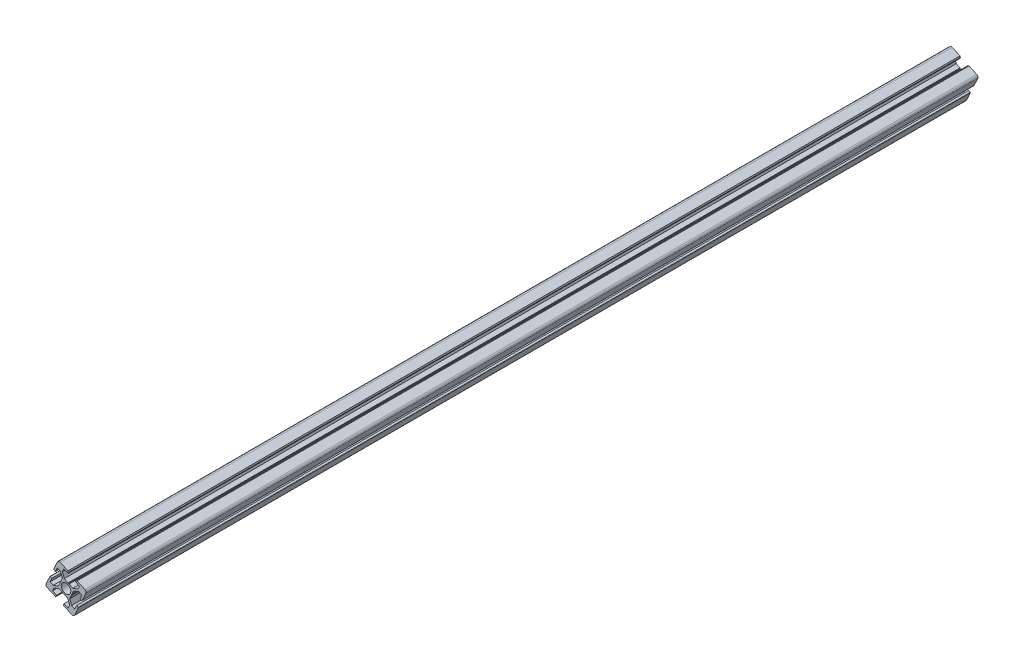
from build123d import *

# Parameters (mm, degrees)
BOSS_EXTRUDE1_DEPTH = 2000
SCALE1_SCALE        = 3
SKETCH2_R           = 115.047789556
CUT_EXTRUDE1_DEPTH  = 1600
SKETCH3_R           = 13.75
CUT_EXTRUDE2_DEPTH  = 4401
SCALE2_SCALE        = 0.466666667
CUT_EXTRUDE3_DEPTH  = 53.3
CUT_EXTRUDE4_DEPTH  = 800


with BuildPart() as part:
    # Sketch1 → Boss-Extrude1 (new body)
    with BuildSketch(Plane.XY):
        with BuildLine():
            Line((-8.216270499, 18.069114507), (-11.842563011, 10.160890774))
            ThreePointArc((-11.842563011, 10.160890774), (-11.851111664, 9.931439908), (-11.694910211, 9.763148835))
            Line((-11.694910211, 9.763148835), (-10.149625113, 9.054562941))
            Line((-10.149625113, 9.054562941), (-8.37816038, 12.917775685))
            Line((-8.37816038, 12.917775685), (-5.345959751, 11.527369089))
            Line((-5.345959751, 11.527369089), (-3.542521768, 6.669331059))
            Line((-3.542521768, 6.669331059), (-5.237363855, 2.973217088))
            Line((-5.237363855, 2.973217088), (-5.181250032, 2.375846818))
            Line((-5.181250032, 2.375846818), (-5.67053095, 2.028565688))
            Line((-5.67053095, 2.028565688), (-7.365373037, -1.667548284))
            Line((-7.365373037, -1.667548284), (-12.223411067, -3.470986267))
            Line((-12.223411067, -3.470986267), (-15.255611696, -2.080579672))
            Line((-15.255611696, -2.080579672), (-13.484146963, 1.782633072))
            Line((-13.484146963, 1.782633072), (-15.029432061, 2.491218965))
            ThreePointArc((-15.029432061, 2.491218965), (-15.258882927, 2.499767617), (-15.427174, 2.343566164))
            Line((-15.427174, 2.343566164), (-19.053466512, -5.564657569))
            ThreePointArc((-19.053466512, -5.564657569), (-19.110457529, -7.094330009), (-18.069114507, -8.216270499))
            Line((-18.069114507, -8.216270499), (-10.160890774, -11.842563011))
            ThreePointArc((-10.160890774, -11.842563011), (-9.931439908, -11.851111664), (-9.763148835, -11.694910211))
            Line((-9.763148835, -11.694910211), (-9.054562941, -10.149625113))
            Line((-9.054562941, -10.149625113), (-12.917775685, -8.37816038))
            Line((-12.917775685, -8.37816038), (-11.527369089, -5.345959751))
            Line((-11.527369089, -5.345959751), (-6.669331059, -3.542521768))
            Line((-6.669331059, -3.542521768), (-2.973217088, -5.237363855))
            Line((-2.973217088, -5.237363855), (-2.375846818, -5.181250032))
            Line((-2.375846818, -5.181250032), (-2.028565688, -5.67053095))
            Line((-2.028565688, -5.67053095), (1.667548284, -7.365373037))
            Line((1.667548284, -7.365373037), (3.470986267, -12.223411067))
            Line((3.470986267, -12.223411067), (2.080579672, -15.255611696))
            Line((2.080579672, -15.255611696), (-1.782633072, -13.484146963))
            Line((-1.782633072, -13.484146963), (-2.491218965, -15.029432061))
            ThreePointArc((-2.491218965, -15.029432061), (-2.499767617, -15.258882927), (-2.343566164, -15.427174))
            Line((-2.343566164, -15.427174), (5.564657569, -19.053466512))
            ThreePointArc((5.564657569, -19.053466512), (7.094330009, -19.110457529), (8.216270499, -18.069114507))
            Line((8.216270499, -18.069114507), (11.842563011, -10.160890774))
            ThreePointArc((11.842563011, -10.160890774), (11.851111664, -9.931439908), (11.694910211, -9.763148835))
            Line((11.694910211, -9.763148835), (10.149625113, -9.054562941))
            Line((10.149625113, -9.054562941), (8.37816038, -12.917775685))
            Line((8.37816038, -12.917775685), (5.345959751, -11.527369089))
            Line((5.345959751, -11.527369089), (3.542521768, -6.669331059))
            Line((3.542521768, -6.669331059), (5.237363855, -2.973217088))
            Line((5.237363855, -2.973217088), (5.181250032, -2.375846818))
            Line((5.181250032, -2.375846818), (5.67053095, -2.028565688))
            Line((5.67053095, -2.028565688), (7.365373037, 1.667548284))
            Line((7.365373037, 1.667548284), (12.223411067, 3.470986267))
            Line((12.223411067, 3.470986267), (15.255611696, 2.080579672))
            Line((15.255611696, 2.080579672), (13.484146963, -1.782633072))
            Line((13.484146963, -1.782633072), (15.029432061, -2.491218965))
            ThreePointArc((15.029432061, -2.491218965), (15.258882927, -2.499767617), (15.427174, -2.343566164))
            Line((15.427174, -2.343566164), (19.053466512, 5.564657569))
            ThreePointArc((19.053466512, 5.564657569), (19.110457529, 7.094330009), (18.069114507, 8.216270499))
            Line((18.069114507, 8.216270499), (10.597022809, 11.642575962))
            Line((10.597022809, 11.642575962), (9.413078742, 11.203063202))
            Line((9.413078742, 11.203063202), (8.951663933, 10.196809148))
            Line((8.951663933, 10.196809148), (12.917775685, 8.37816038))
            Line((12.917775685, 8.37816038), (11.527369089, 5.345959751))
            Line((11.527369089, 5.345959751), (6.669331059, 3.542521768))
            Line((6.669331059, 3.542521768), (2.973217088, 5.237363855))
            Line((2.973217088, 5.237363855), (2.375846818, 5.181250032))
            Line((2.375846818, 5.181250032), (2.028565688, 5.67053095))
            Line((2.028565688, 5.67053095), (-1.667548284, 7.365373037))
            Line((-1.667548284, 7.365373037), (-3.470986267, 12.223411067))
            Line((-3.470986267, 12.223411067), (-2.080579672, 15.255611696))
            Line((-2.080579672, 15.255611696), (1.88553208, 13.436962929))
            Line((1.88553208, 13.436962929), (2.346946889, 14.443216983))
            Line((2.346946889, 14.443216983), (1.907434129, 15.62716105))
            Line((1.907434129, 15.62716105), (-5.564657569, 19.053466512))
            ThreePointArc((-5.564657569, 19.053466512), (-7.094330009, 19.110457529), (-8.216270499, 18.069114507))
        make_face()
    extrude(amount=BOSS_EXTRUDE1_DEPTH)


with BuildPart() as part_1:
    # Scale1: scaled about (-0.00473582, -0.010327884, 1000)
    add(part.part.scale(SCALE1_SCALE).moved(Location((0.00947164, 0.020655768, -2000))))

    # Sketch2 → Cut-Extrude1 (cut)
    with BuildSketch(Plane(origin=(0, 0, -2000), x_dir=(-1, 0, 0), z_dir=(0, 0, -1))):
        Circle(SKETCH2_R)
    extrude(amount=-CUT_EXTRUDE1_DEPTH, mode=Mode.SUBTRACT)

    # Sketch3 → Cut-Extrude2 (cut, through all)
    with BuildSketch(Plane.XY.offset(4000)):
        Circle(SKETCH3_R)
    extrude(amount=-CUT_EXTRUDE2_DEPTH, mode=Mode.SUBTRACT)


with BuildPart() as part_2:
    # Scale2: scaled about (-0.005610815, -0.012236071, 1800)
    add(part_1.part.scale(SCALE2_SCALE).moved(Location((-0.002992435, -0.006525905, 960))))

    # Sketch6 → Cut-Extrude3 (cut)
    with BuildSketch(Plane(origin=(0, 0, 773.333333333), x_dir=(-1, 0, 0), z_dir=(0, 0, -1))):
        with BuildLine():
            Line((7.789092932, 26.67796657), (-2.671835446, 21.881138923))
            Line((-2.671835446, 21.881138923), (-3.287153309, 20.223617229))
            Line((-3.287153309, 20.223617229), (-2.641172576, 18.814861553))
            Line((-2.641172576, 18.814861553), (2.911383876, 21.360969828))
            Line((2.911383876, 21.360969828), (4.857953109, 17.115888947))
            Line((4.857953109, 17.115888947), (2.333139933, 10.314635704))
            Line((2.333139933, 10.314635704), (-2.841419627, 7.941856782))
            Line((-2.841419627, 7.941856782), (-3.32761321, 7.256863498))
            Line((-3.32761321, 7.256863498), (-4.163931587, 7.33542285))
            Line((-4.163931587, 7.33542285), (-9.338491147, 4.962643928))
            Line((-9.338491147, 4.962643928), (-16.13974439, 7.487457104))
            Line((-16.13974439, 7.487457104), (-18.086313623, 11.732537985))
            Line((-18.086313623, 11.732537985), (-12.533757171, 14.27864626))
            Line((-12.533757171, 14.27864626), (-13.179737904, 15.687401936))
            Line((-13.179737904, 15.687401936), (-14.837259597, 16.302719799))
            Line((-14.837259597, 16.302719799), (-25.298187975, 11.505892152))
            ThreePointArc((-25.298187975, 11.505892152), (-26.756068205, 9.935175466), (-26.676280782, 7.79363405))
            Line((-26.676280782, 7.79363405), (-21.599471265, -3.277879177))
            ThreePointArc((-21.599471265, -3.277879177), (-21.363863762, -3.496561211), (-21.04263255, -3.484593098))
            Line((-21.04263255, -3.484593098), (-18.879233413, -2.492572848))
            Line((-18.879233413, -2.492572848), (-21.359284039, 2.915924993))
            Line((-21.359284039, 2.915924993), (-17.114203158, 4.862494227))
            Line((-17.114203158, 4.862494227), (-10.312949916, 2.33768105))
            Line((-10.312949916, 2.33768105), (-7.940170994, -2.83687851))
            Line((-7.940170994, -2.83687851), (-7.25517771, -3.323072093))
            Line((-7.25517771, -3.323072093), (-7.333737061, -4.15939047))
            Line((-7.333737061, -4.15939047), (-4.960958139, -9.33395003))
            Line((-4.960958139, -9.33395003), (-7.485771316, -16.135203272))
            Line((-7.485771316, -16.135203272), (-11.730852197, -18.081772506))
            Line((-11.730852197, -18.081772506), (-14.210902823, -12.673274665))
            Line((-14.210902823, -12.673274665), (-16.374301959, -13.665294916))
            ThreePointArc((-16.374301959, -13.665294916), (-16.592983994, -13.900902418), (-16.58101588, -14.222133631))
            Line((-16.58101588, -14.222133631), (-11.504206363, -25.293646858))
            ThreePointArc((-11.504206363, -25.293646858), (-9.933489678, -26.751527087), (-7.791948261, -26.671739664))
            Line((-7.791948261, -26.671739664), (3.279564965, -21.594930148))
            ThreePointArc((3.279564965, -21.594930148), (3.498247, -21.359322645), (3.486278886, -21.038091432))
            Line((3.486278886, -21.038091432), (2.494258636, -18.874692296))
            Line((2.494258636, -18.874692296), (-2.914239205, -21.354742922))
            Line((-2.914239205, -21.354742922), (-4.860808438, -17.109662041))
            Line((-4.860808438, -17.109662041), (-2.335995262, -10.308408799))
            Line((-2.335995262, -10.308408799), (2.838564298, -7.935629877))
            Line((2.838564298, -7.935629877), (3.324757881, -7.250636592))
            Line((3.324757881, -7.250636592), (4.161076258, -7.329195944))
            Line((4.161076258, -7.329195944), (9.335635818, -4.956417022))
            Line((9.335635818, -4.956417022), (16.13688906, -7.481230198))
            Line((16.13688906, -7.481230198), (18.083458294, -11.72631108))
            Line((18.083458294, -11.72631108), (12.674960453, -14.206361706))
            Line((12.674960453, -14.206361706), (13.666980704, -16.369760842))
            ThreePointArc((13.666980704, -16.369760842), (13.902588207, -16.588442876), (14.223819419, -16.576474763))
            Line((14.223819419, -16.576474763), (25.295332646, -11.499665246))
            ThreePointArc((25.295332646, -11.499665246), (26.753212876, -9.92894856), (26.673425453, -7.787407144))
            Line((26.673425453, -7.787407144), (21.596615936, 3.284106083))
            ThreePointArc((21.596615936, 3.284106083), (21.361008433, 3.502788117), (21.039777221, 3.490820004))
            Line((21.039777221, 3.490820004), (18.876378084, 2.498799753))
            Line((18.876378084, 2.498799753), (21.35642871, -2.909698087))
            Line((21.35642871, -2.909698087), (17.111347829, -4.856267321))
            Line((17.111347829, -4.856267321), (10.310094587, -2.331454145))
            Line((10.310094587, -2.331454145), (7.937315665, 2.843105415))
            Line((7.937315665, 2.843105415), (7.252322381, 3.329298998))
            Line((7.252322381, 3.329298998), (7.330881732, 4.165617376))
            Line((7.330881732, 4.165617376), (4.95810281, 9.340176936))
            Line((4.95810281, 9.340176936), (7.482915987, 16.141430178))
            Line((7.482915987, 16.141430178), (11.727996868, 18.087999412))
            Line((11.727996868, 18.087999412), (14.208047494, 12.679501571))
            Line((14.208047494, 12.679501571), (16.37144663, 13.671521821))
            ThreePointArc((16.37144663, 13.671521821), (16.590128665, 13.907129324), (16.578160551, 14.228360537))
            Line((16.578160551, 14.228360537), (11.501351034, 25.299873763))
            ThreePointArc((11.501351034, 25.299873763), (9.930634349, 26.757753993), (7.789092932, 26.67796657))
        make_face()
    extrude(amount=-CUT_EXTRUDE3_DEPTH, mode=Mode.SUBTRACT)

    # Sketch7 → Cut-Extrude4 (cut)
    with BuildSketch(Plane(origin=(0, 0, 826.633333333), x_dir=(-1, 0, 0), z_dir=(0, 0, -1))):
        with BuildLine():
            Line((7.789092932, 26.67796657), (-2.671835446, 21.881138923))
            Line((-2.671835446, 21.881138923), (-3.287153309, 20.223617229))
            Line((-3.287153309, 20.223617229), (-2.641172576, 18.814861553))
            Line((-2.641172576, 18.814861553), (2.911383876, 21.360969828))
            Line((2.911383876, 21.360969828), (4.857953109, 17.115888947))
            Line((4.857953109, 17.115888947), (2.333139933, 10.314635704))
            Line((2.333139933, 10.314635704), (-2.841419627, 7.941856782))
            Line((-2.841419627, 7.941856782), (-3.32761321, 7.256863498))
            Line((-3.32761321, 7.256863498), (-4.163931587, 7.33542285))
            Line((-4.163931587, 7.33542285), (-9.338491147, 4.962643928))
            Line((-9.338491147, 4.962643928), (-16.13974439, 7.487457104))
            Line((-16.13974439, 7.487457104), (-18.086313623, 11.732537985))
            Line((-18.086313623, 11.732537985), (-12.533757171, 14.27864626))
            Line((-12.533757171, 14.27864626), (-13.179737904, 15.687401936))
            Line((-13.179737904, 15.687401936), (-14.837259597, 16.302719799))
            Line((-14.837259597, 16.302719799), (-25.298187975, 11.505892152))
            ThreePointArc((-25.298187975, 11.505892152), (-26.756068205, 9.935175466), (-26.676280782, 7.79363405))
            Line((-26.676280782, 7.79363405), (-21.599471265, -3.277879177))
            ThreePointArc((-21.599471265, -3.277879177), (-21.363863762, -3.496561211), (-21.04263255, -3.484593098))
            Line((-21.04263255, -3.484593098), (-18.879233413, -2.492572848))
            Line((-18.879233413, -2.492572848), (-21.359284039, 2.915924993))
            Line((-21.359284039, 2.915924993), (-17.114203158, 4.862494227))
            Line((-17.114203158, 4.862494227), (-10.312949916, 2.33768105))
            Line((-10.312949916, 2.33768105), (-7.940170994, -2.83687851))
            Line((-7.940170994, -2.83687851), (-7.25517771, -3.323072093))
            Line((-7.25517771, -3.323072093), (-7.333737061, -4.15939047))
            Line((-7.333737061, -4.15939047), (-4.960958139, -9.33395003))
            Line((-4.960958139, -9.33395003), (-7.485771316, -16.135203272))
            Line((-7.485771316, -16.135203272), (-11.730852197, -18.081772506))
            Line((-11.730852197, -18.081772506), (-14.210902823, -12.673274665))
            Line((-14.210902823, -12.673274665), (-16.374301959, -13.665294916))
            ThreePointArc((-16.374301959, -13.665294916), (-16.592983994, -13.900902418), (-16.58101588, -14.222133631))
            Line((-16.58101588, -14.222133631), (-11.504206363, -25.293646858))
            ThreePointArc((-11.504206363, -25.293646858), (-9.933489678, -26.751527087), (-7.791948261, -26.671739664))
            Line((-7.791948261, -26.671739664), (3.279564965, -21.594930148))
            ThreePointArc((3.279564965, -21.594930148), (3.498247, -21.359322645), (3.486278886, -21.038091432))
            Line((3.486278886, -21.038091432), (2.494258636, -18.874692296))
            Line((2.494258636, -18.874692296), (-2.914239205, -21.354742922))
            Line((-2.914239205, -21.354742922), (-4.860808438, -17.109662041))
            Line((-4.860808438, -17.109662041), (-2.335995262, -10.308408799))
            Line((-2.335995262, -10.308408799), (2.838564298, -7.935629877))
            Line((2.838564298, -7.935629877), (3.324757881, -7.250636592))
            Line((3.324757881, -7.250636592), (4.161076258, -7.329195944))
            Line((4.161076258, -7.329195944), (9.335635818, -4.956417022))
            Line((9.335635818, -4.956417022), (16.13688906, -7.481230198))
            Line((16.13688906, -7.481230198), (18.083458294, -11.72631108))
            Line((18.083458294, -11.72631108), (12.674960453, -14.206361706))
            Line((12.674960453, -14.206361706), (13.666980704, -16.369760842))
            ThreePointArc((13.666980704, -16.369760842), (13.902588207, -16.588442876), (14.223819419, -16.576474763))
            Line((14.223819419, -16.576474763), (25.295332646, -11.499665246))
            ThreePointArc((25.295332646, -11.499665246), (26.753212876, -9.92894856), (26.673425453, -7.787407144))
            Line((26.673425453, -7.787407144), (21.596615936, 3.284106083))
            ThreePointArc((21.596615936, 3.284106083), (21.361008433, 3.502788117), (21.039777221, 3.490820004))
            Line((21.039777221, 3.490820004), (18.876378084, 2.498799753))
            Line((18.876378084, 2.498799753), (21.35642871, -2.909698087))
            Line((21.35642871, -2.909698087), (17.111347829, -4.856267321))
            Line((17.111347829, -4.856267321), (10.310094587, -2.331454145))
            Line((10.310094587, -2.331454145), (7.937315665, 2.843105415))
            Line((7.937315665, 2.843105415), (7.252322381, 3.329298998))
            Line((7.252322381, 3.329298998), (7.330881732, 4.165617376))
            Line((7.330881732, 4.165617376), (4.95810281, 9.340176936))
            Line((4.95810281, 9.340176936), (7.482915987, 16.141430178))
            Line((7.482915987, 16.141430178), (11.727996868, 18.087999412))
            Line((11.727996868, 18.087999412), (14.208047494, 12.679501571))
            Line((14.208047494, 12.679501571), (16.37144663, 13.671521821))
            ThreePointArc((16.37144663, 13.671521821), (16.590128665, 13.907129324), (16.578160551, 14.228360537))
            Line((16.578160551, 14.228360537), (11.501351034, 25.299873763))
            ThreePointArc((11.501351034, 25.299873763), (9.930634349, 26.757753993), (7.789092932, 26.67796657))
        make_face()
    extrude(amount=-CUT_EXTRUDE4_DEPTH, mode=Mode.SUBTRACT)


solid = part_2.part
